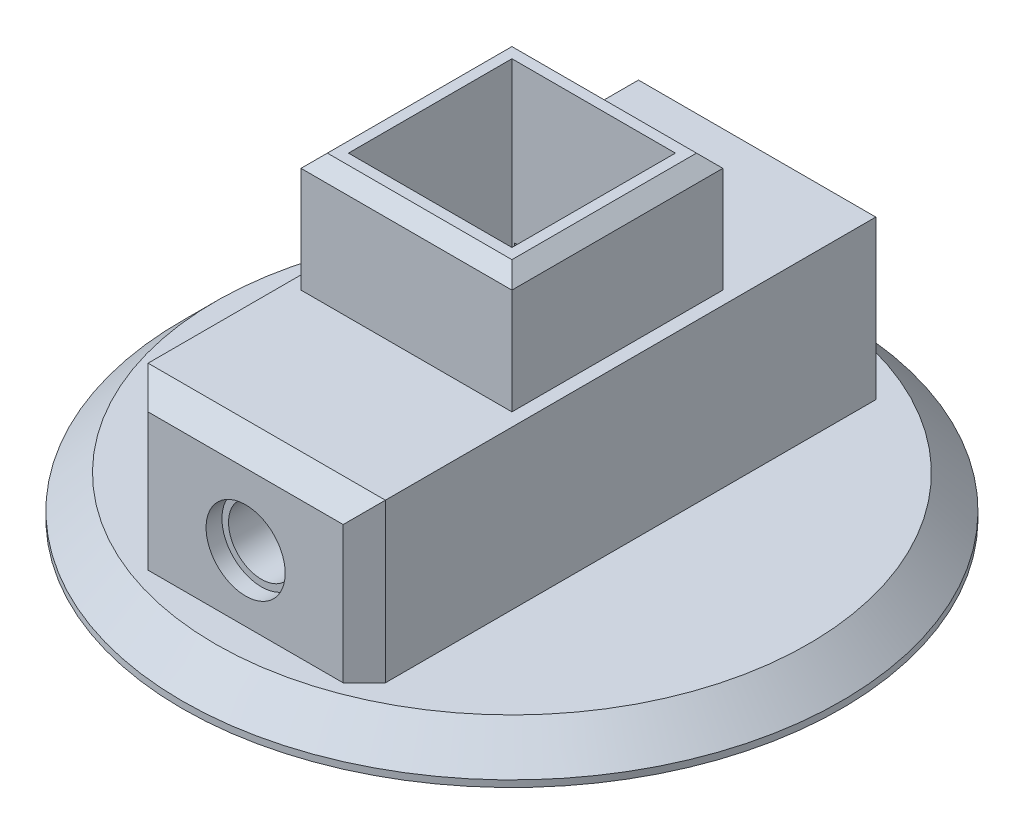
from build123d import *

# Parameters (mm, degrees)
SKETCH1_W           = 16
SKETCH1_H           = 16
BOSS_EXTRUDE1_DEPTH = 24
SKETCH12_W          = 12.4
SKETCH12_H          = 12.4
CUT_EXTRUDE6_DEPTH  = 22
SKETCH13_R          = 25
BOSS_EXTRUDE2_DEPTH = 3
CHAMFER1_SIZE       = 2.5
SKETCH14_W          = 18
SKETCH14_H          = 40.4
SKETCH14_W_2        = 16
SKETCH14_H_2        = 16
BOSS_EXTRUDE3_DEPTH = 12
CHAMFER2_SIZE       = 1.6
CHAMFER5_SIZE       = 1
SKETCH16_W          = 12
SKETCH16_H          = 8
CUT_EXTRUDE8_DEPTH  = 14
SKETCH15_R          = 1.3
CUT_EXTRUDE7_DEPTH  = 19.8
SKETCH17_R          = 2.5
CUT_EXTRUDE9_DEPTH  = 9
SKETCH19_R          = 3
CUT_EXTRUDE10_DEPTH = 1.2


with BuildPart() as part:
    # Sketch1 → Boss-Extrude1 (new body)
    with BuildSketch(Plane(origin=(0, 0, 0), x_dir=(1, 0, 0), z_dir=(0, 1, 0))):
        with Locations((0, 8)):
            Rectangle(SKETCH1_W, SKETCH1_H)
    extrude(amount=BOSS_EXTRUDE1_DEPTH)

    # Sketch12 → Cut-Extrude6 (cut)
    with BuildSketch(Plane(origin=(0, 24, 0), x_dir=(1, 0, 0), z_dir=(0, 1, 0))):
        with Locations((0, 8)):
            Rectangle(SKETCH12_W, SKETCH12_H)
    extrude(amount=-CUT_EXTRUDE6_DEPTH, mode=Mode.SUBTRACT)

    # Sketch13 → Boss-Extrude2 (add)
    with BuildSketch(Plane(origin=(0, 0, 0), x_dir=(1, 0, 0), z_dir=(0, 1, 0))):
        with Locations((0, 8)):
            Circle(SKETCH13_R)
    extrude(amount=BOSS_EXTRUDE2_DEPTH)

    # Chamfer1
    chamfer1_edges = [part.edges().sort_by_distance(p)[0] for p in [
        (-25, 3, -8),
    ]]
    chamfer(chamfer1_edges, length=CHAMFER1_SIZE)

    # Sketch14 → Boss-Extrude3 (add)
    with BuildSketch(Plane(origin=(0, 3, 0), x_dir=(1, 0, 0), z_dir=(0, 1, 0))):
        with Locations((0, 8)):
            Rectangle(SKETCH14_W, SKETCH14_H)
        with Locations((0, 8)):
            Rectangle(SKETCH14_W_2, SKETCH14_H_2, mode=Mode.SUBTRACT)
    extrude(amount=BOSS_EXTRUDE3_DEPTH)

    # Chamfer2
    chamfer2_edges = [part.edges().sort_by_distance(p)[0] for p in [
        (0, 15, 12.2),
        (0, 15, -28.2),
        (-9, 9, 12.2),
        (9, 9, 12.2),
        (9, 9, -28.2),
        (-9, 9, -28.2),
    ]]
    chamfer(chamfer2_edges, length=CHAMFER2_SIZE)

    # Chamfer5
    chamfer5_edges = [part.edges().sort_by_distance(p)[0] for p in [
        (0, 24, -16),
        (-8, 24, -8),
        (0, 24, 0),
        (8, 24, -8),
    ]]
    chamfer(chamfer5_edges, length=CHAMFER5_SIZE)

    # Sketch16 → Cut-Extrude8 (cut)
    with BuildSketch(Plane(origin=(0, 0, -28.2), x_dir=(-1, 0, 0), z_dir=(0, 0, -1))):
        with Locations((0, 8)):
            Rectangle(SKETCH16_W, SKETCH16_H)
    extrude(amount=-CUT_EXTRUDE8_DEPTH, mode=Mode.SUBTRACT)

    # Sketch15 → Cut-Extrude7 (cut, through all)
    with BuildSketch(Plane(origin=(0, 0, -1.8), x_dir=(-1, 0, 0), z_dir=(0, 0, -1))):
        with Locations((0, 8)):
            Circle(SKETCH15_R)
    extrude(amount=-CUT_EXTRUDE7_DEPTH, mode=Mode.SUBTRACT)

    # Sketch17 → Cut-Extrude9 (cut)
    with BuildSketch(Plane.XY.offset(12.2)):
        with Locations((0, 8)):
            Circle(SKETCH17_R)
    extrude(amount=-CUT_EXTRUDE9_DEPTH, mode=Mode.SUBTRACT)

    # Sketch19 → Cut-Extrude10 (cut)
    with BuildSketch(Plane.XY.offset(12.2)):
        with Locations((0, 8)):
            Circle(SKETCH19_R)
    extrude(amount=-CUT_EXTRUDE10_DEPTH, mode=Mode.SUBTRACT)


solid = part.part
